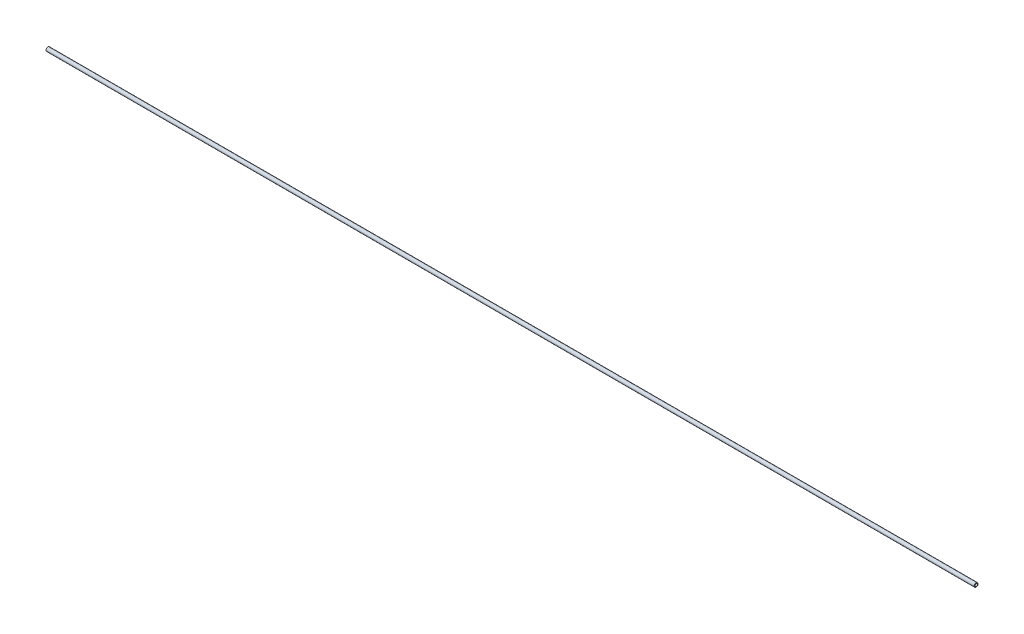
from build123d import *

# Parameters (mm, degrees)
SKETCH1_R      = 3.175
SKETCH1_R_2    = 1.9304
EXTRUDE1_DEPTH = 1524
CHAMFER1_SIZE  = 0.381


with BuildPart() as part:
    # Sketch1 → Extrude1 (new body)
    with BuildSketch(Plane.ZY):
        Circle(SKETCH1_R)
        Circle(SKETCH1_R_2, mode=Mode.SUBTRACT)
    extrude(amount=EXTRUDE1_DEPTH)

    # Chamfer1
    chamfer1_edges = [part.edges().sort_by_distance(p)[0] for p in [
        (0, 0, -3.175),
        (-1524, 0, -3.175),
    ]]
    chamfer(chamfer1_edges, length=CHAMFER1_SIZE)


solid = part.part
